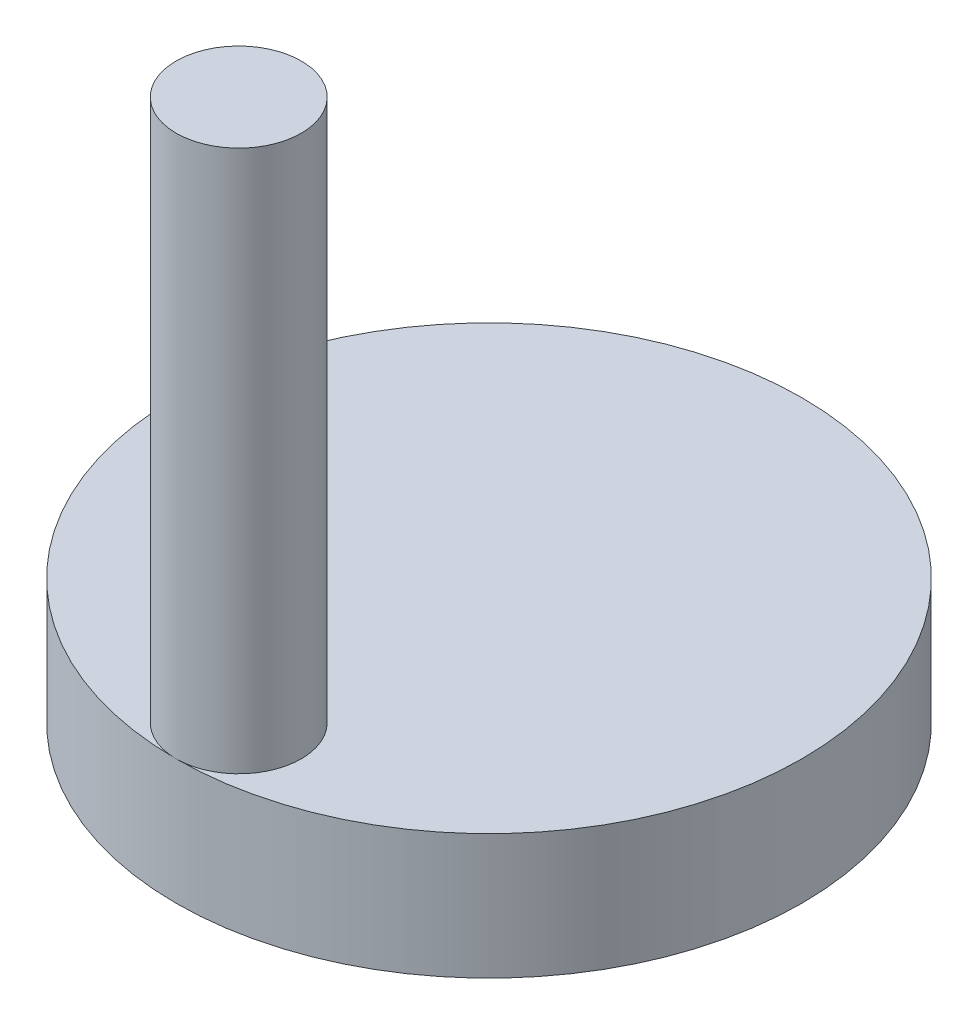
from build123d import *

# Parameters (mm, degrees)
ESQUISSE1_R        = 25
BOSS_EXTRU_1_DEPTH = 10
ESQUISSE2_R        = 5
BOSS_EXTRU_2_DEPTH = 43.3


with BuildPart() as part:
    # Esquisse1 → Boss.-Extru.1 (new body)
    with BuildSketch(Plane(origin=(0, 0, 0), x_dir=(1, 0, 0), z_dir=(0, 1, 0))):
        with Locations(Location((0, 0, 0), (0, 0, 270))):  # turned: the seam where the file's is
            Circle(ESQUISSE1_R)
    extrude(amount=BOSS_EXTRU_1_DEPTH)

    # Esquisse2 → Boss.-Extru.2 (add)
    with BuildSketch(Plane(origin=(0, 10, 0), x_dir=(1, 0, 0), z_dir=(0, 1, 0))):
        with Locations(Location((0, -20, 0), (0, 0, 270))):  # turned: the seam where the file's is
            Circle(ESQUISSE2_R)
    extrude(amount=BOSS_EXTRU_2_DEPTH)


solid = part.part
